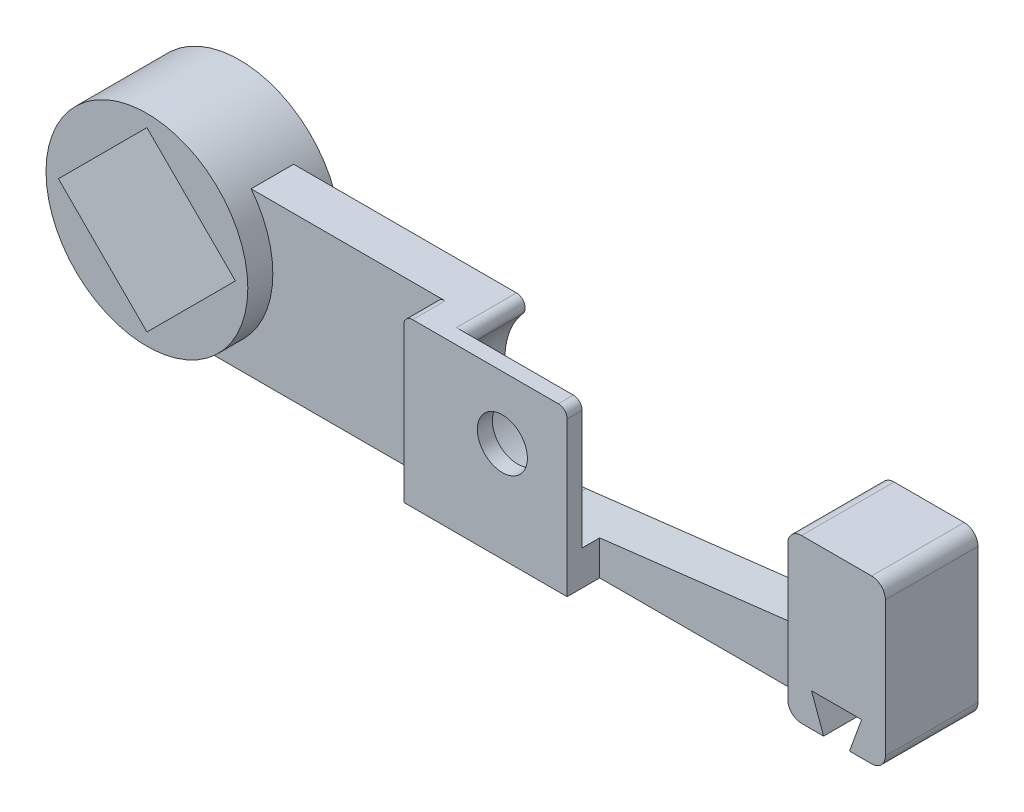
from build123d import *

# Parameters (mm, degrees)
SKETCH1_W           = 38.1
SKETCH1_H           = 2.159
BOSS_EXTRUDE1_DEPTH = 8.255
CUT_EXTRUDE1_DEPTH  = 12.7
FILLET5_R           = 0.4826
FILLET7_R           = 0.4445
SKETCH3_W           = 4.953
SKETCH3_H           = 8.255
BOSS_EXTRUDE2_DEPTH = 1.27
CUT_EXTRUDE4_DEPTH  = 5.699
FILLET9_R           = 0.6985
SKETCH4_R           = 5.11953367
BOSS_EXTRUDE3_DEPTH = 4.699
CUT_EXTRUDE3_DEPTH  = 4.699
BOSS_EXTRUDE4_DEPTH = 0.889
SKETCH10_W          = 8.28565978
SKETCH10_H          = 8.255
BOSS_EXTRUDE5_DEPTH = 0.762
FILLET10_R          = 0.4445
SKETCH11_R          = 1.27
CUT_EXTRUDE5_DEPTH  = 1.762


with BuildPart() as part:
    # Sketch1 → Boss-Extrude1 (new body)
    with BuildSketch(Plane(origin=(0, 0, 0), x_dir=(1, 0, 0), z_dir=(0, 1, 0))):
        Rectangle(SKETCH1_W, SKETCH1_H)
    extrude(amount=BOSS_EXTRUDE1_DEPTH)

    # Sketch2 → Cut-Extrude1 (cut)
    with BuildSketch(Plane.XY.offset(1.0795)):
        with BuildLine():
            Line((0.435059279, 1.422786249), (14.097, 3.048))
            ThreePointArc((14.097, 3.048), (15.901602081, 5.08), (14.097, 7.112))
            Line((14.097, 7.112), (14.839370062, 13.352542684))
            Line((14.839370062, 13.352542684), (0.435059279, 13.41059889))
            Line((0.435059279, 13.41059889), (-0.435059279, 13.41059889))
            Line((-0.435059279, 13.41059889), (0, 8.763))
            ThreePointArc((0, 8.763), (-3.676547786, 5.297911397), (-0.435059279, 1.422786249))
            ThreePointArc((-0.435059279, 1.422786249), (0, 1.397), (0.435059279, 1.422786249))
        make_face()
    extrude(amount=-CUT_EXTRUDE1_DEPTH, mode=Mode.SUBTRACT)

    # Fillet5
    fillet5_edges = [part.edges().sort_by_distance(p)[0] for p in [
        (14.232970383, 8.255, 0),
        (14.097, 7.112, 0),
    ]]
    fillet(fillet5_edges, radius=FILLET5_R)

    # Fillet7
    fillet7_edges = [part.edges().sort_by_distance(p)[0] for p in [
        (-1.866511184, 8.255, 0),
    ]]
    fillet(fillet7_edges, radius=FILLET7_R)

    # Sketch3 → Boss-Extrude2 (add)
    with BuildSketch(Plane.XY.offset(1.0795)):
        with Locations((16.5735, 4.1275)):
            Rectangle(SKETCH3_W, SKETCH3_H)
    boss_extrude2 = extrude(amount=BOSS_EXTRUDE2_DEPTH)

    # Mirror2: Boss-Extrude2 across plane
    add(boss_extrude2.mirror(Plane.XY))

    # Sketch8 → Cut-Extrude4 (cut, through all)
    with BuildSketch(Plane.XY.offset(2.3495)):
        Polygon((15.3035, 1.6891), (17.8435, 1.6891), (17.228717877, 0), (15.918282123, 0), align=None)
    extrude(amount=-CUT_EXTRUDE4_DEPTH, mode=Mode.SUBTRACT)

    # Fillet9
    fillet9_edges = [part.edges().sort_by_distance(p)[0] for p in [
        (14.097, 0, -1.7145),
        (14.097, 0, 1.7145),
        (14.097, 8.255, -1.7145),
        (19.05, 0, 0),
        (19.05, 8.255, 0),
    ]]
    fillet(fillet9_edges, radius=FILLET9_R)

    # Sketch4 → Boss-Extrude3 (add)
    with BuildSketch(Plane.XY.offset(2.3495)):
        with Locations((-18.415, 5.08)):
            Circle(SKETCH4_R)
        Polygon((-18.415, 0.589871939), (-22.905128061, 5.08), (-18.415, 9.570128061), (-13.924871939, 5.08), align=None, mode=Mode.SUBTRACT)
    extrude(amount=-BOSS_EXTRUDE3_DEPTH)

    # Sketch7 → Cut-Extrude3 (cut)
    with BuildSketch(Plane.XY.offset(2.3495)):
        Polygon((-22.905128061, 5.08), (-18.415, 9.570128061), (-13.924871939, 5.08), (-18.415, 0.589871939), align=None)
    extrude(amount=-CUT_EXTRUDE3_DEPTH, mode=Mode.SUBTRACT)

    # Sketch9 → Boss-Extrude4 (add)
    with BuildSketch(Plane.XY.offset(1.0795)):
        with BuildLine():
            Line((-3.095258632, 8.255), (-5.000258632, 8.255))
            Line((-5.000258632, 8.255), (-5.000258632, 0))
            Line((-5.000258632, 0), (0.110401148, 0))
            Line((0.110401148, 0), (3.285401148, 0))
            Line((3.285401148, 0), (3.285401148, 1.761860681))
            Line((3.285401148, 1.761860681), (0.435059279, 1.422786249))
            ThreePointArc((0.435059279, 1.422786249), (-3.261402544, 3.368935289), (-2.761923087, 7.516446154))
            ThreePointArc((-2.761923087, 7.516446154), (-2.690112248, 7.993356932), (-3.095258632, 8.255))
        make_face()
    extrude(amount=BOSS_EXTRUDE4_DEPTH)

    # Sketch10 → Boss-Extrude5 (add)
    with BuildSketch(Plane.XY.offset(1.9685)):
        with Locations((-0.857428742, 4.1275)):
            Rectangle(SKETCH10_W, SKETCH10_H)
    extrude(amount=BOSS_EXTRUDE5_DEPTH)

    # Fillet10
    fillet10_edges = [part.edges().sort_by_distance(p)[0] for p in [
        (-5.000258632, 8.255, 1.905),
        (3.285401148, 8.255, 2.3495),
    ]]
    fillet(fillet10_edges, radius=FILLET10_R)

    # Sketch11 → Cut-Extrude5 (cut, through all)
    with BuildSketch(Plane(origin=(0, 0, 1.9685), x_dir=(-1, 0, 0), z_dir=(0, 0, -1))):
        with Locations((0, 5.08)):
            Circle(SKETCH11_R)
    extrude(amount=-CUT_EXTRUDE5_DEPTH, mode=Mode.SUBTRACT)


solid = part.part
